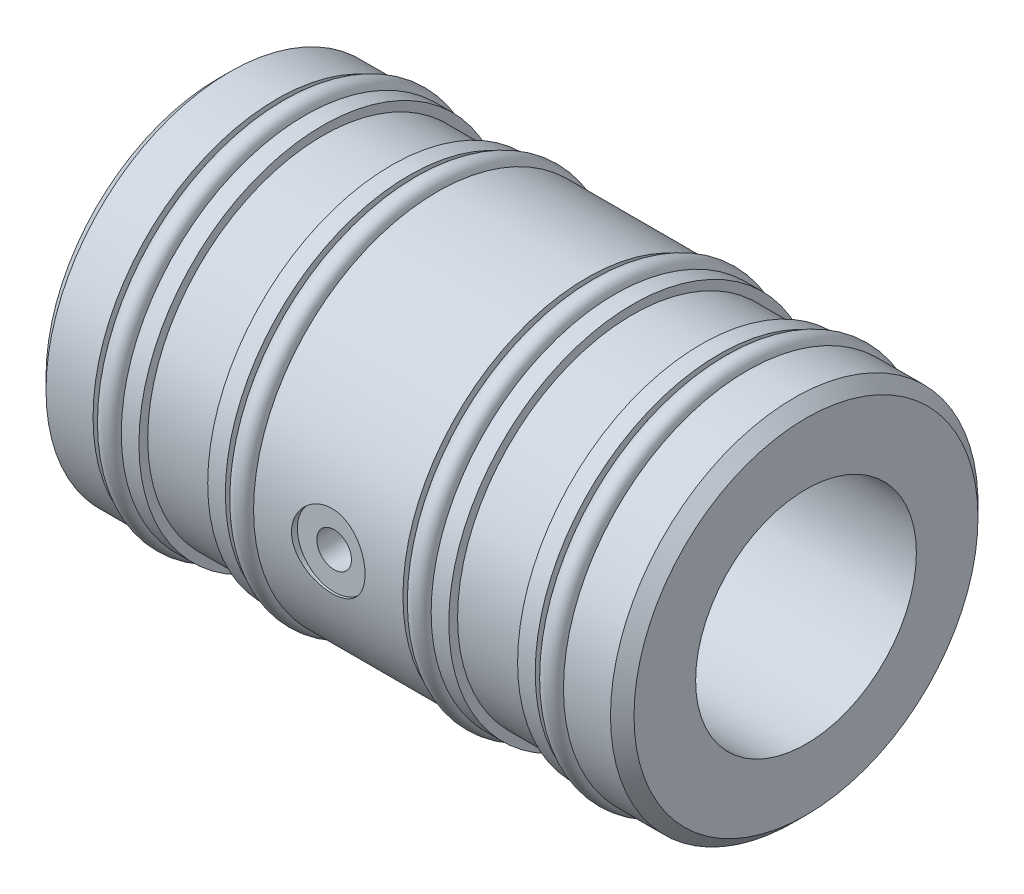
from build123d import *

# Parameters (mm, degrees)
CHAMFER1_SIZE                   = 1.016
F_1_4_0_25_DIAMETER_HOLE1_D     = 6.35
F_1_4_0_25_DIAMETER_HOLE1_DEPTH = 0.508
AIR_HOLE_D                      = 2.4892
AIR_HOLE_DEPTH                  = 6.35
AIR_HOLE_CBORE_D                = 2.9972
AIR_HOLE_CBORE_DEPTH            = 5.9944
AIR_HOLE_TIP                    = 0.747831126
SKETCH5_R                       = 0.87503


with BuildPart() as part:
    # Sketch1 → Revolve1 (revolve)
    with BuildSketch(Plane.XY, mode=Mode.PRIVATE) as revolve1_sk:
        Polygon((0, 9.53516), (50.8, 9.53516), (50.8, 15.875), (45.72, 15.875), (45.72, 14.605), (43.2816, 14.605), (43.2816, 15.875), (41.7576, 15.875), (41.7576, 15.113), (35.814, 15.113), (35.814, 15.875), (34.29, 15.875), (34.29, 14.605), (31.8516, 14.605), (31.8516, 15.875), (18.9484, 15.875), (18.9484, 14.605), (16.51, 14.605), (16.51, 15.875), (14.986, 15.875), (14.986, 15.113), (9.0424, 15.113), (9.0424, 15.875), (7.5184, 15.875), (7.5184, 14.605), (5.08, 14.605), (5.08, 15.875), (0, 15.875), align=None)
    revolve(revolve1_sk.sketch.rotate(Axis((0, 0, 0), (1, 0, 0)), 90), axis=Axis((0, 0, 0), (1, 0, 0)))  # turned: the seam where the file's is

    # Chamfer1
    chamfer1_edges = [part.edges().sort_by_distance(p)[0] for p in [
        (50.8, 0, -15.875),
        (0, 0, -15.875),
    ]]
    chamfer(chamfer1_edges, length=CHAMFER1_SIZE)

    # 1/4 (0.25) Diameter Hole1
    with Locations(Plane(origin=(25.4, 0, 15.875), x_dir=(1, 0, 0), z_dir=(0, 0, 1))):
        with Locations((0, 0)):
            Hole(F_1_4_0_25_DIAMETER_HOLE1_D / 2, depth=F_1_4_0_25_DIAMETER_HOLE1_DEPTH)

    # Air Hole
    with Locations(Plane.XY.offset(15.367)):
        with Locations((25.4, 0)):
            CounterBoreHole(AIR_HOLE_D / 2, AIR_HOLE_CBORE_D / 2, AIR_HOLE_CBORE_DEPTH, depth=AIR_HOLE_DEPTH)
            with Locations((0, 0, -(AIR_HOLE_DEPTH + AIR_HOLE_TIP / 2))):  # 118° drill point
                Cone(0, AIR_HOLE_D / 2, AIR_HOLE_TIP, mode=Mode.SUBTRACT)

    # Sketch5 → Revolve2 (revolve)
    with BuildSketch(Plane.XY, mode=Mode.PRIVATE) as revolve2_sk:
        with Locations((6.2992, 15.47749)):
            Circle(SKETCH5_R)
        with Locations((17.7292, 15.47749)):
            Circle(SKETCH5_R)
        with Locations((33.0708, 15.47749)):
            Circle(SKETCH5_R)
        with Locations((44.5008, 15.47749)):
            Circle(SKETCH5_R)
    revolve(revolve2_sk.sketch.rotate(Axis((0, 0, 0), (1, 0, 0)), 90), axis=Axis((0, 0, 0), (1, 0, 0)))  # turned: the seam where the file's is


solid = part.part
